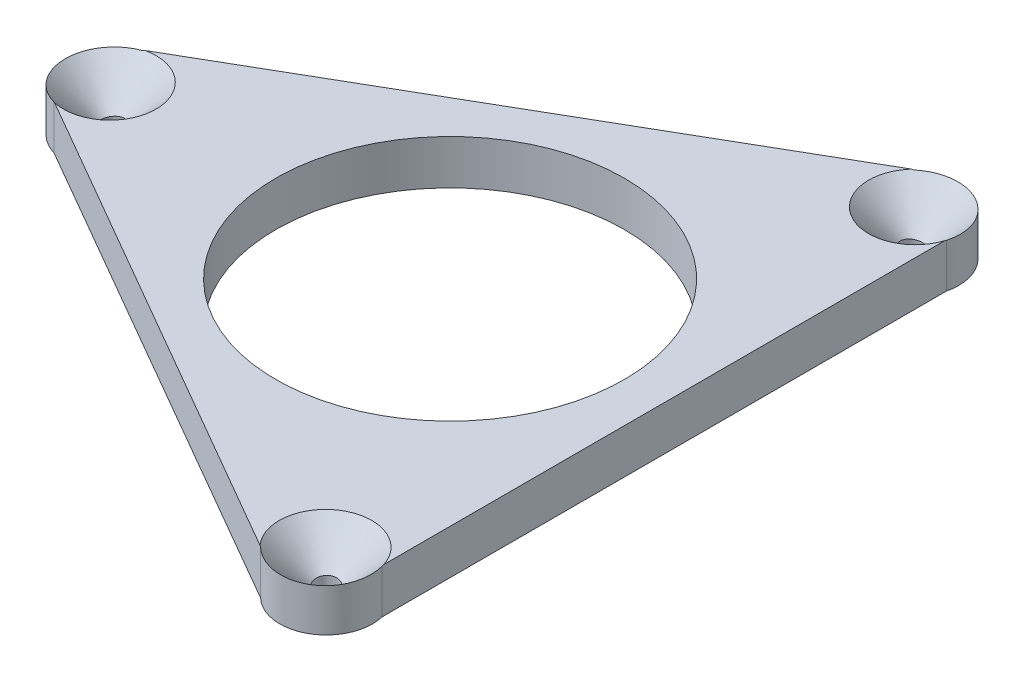
from build123d import *

# Parameters (mm, degrees)
SKETCH1_R           = 5.969
BOSS_EXTRUDE1_DEPTH = 1.524
CIRPATTERN1_COUNT   = 3
SKETCH4_R           = 0.381
CUT_EXTRUDE2_DEPTH  = 12.7


with BuildPart() as part:
    # Sketch1 → Boss-Extrude1 (new body)
    with BuildSketch(Plane(origin=(0, 0, 0), x_dir=(1, 0, 0), z_dir=(0, 1, 0))):
        with BuildLine():
            Line((-12.0345, -1.524), (4.697427285, -11.184182722))
            ThreePointArc((4.697427285, -11.184182722), (6.58875, -11.412049758), (7.337072715, -9.660182722))
            Line((7.337072715, -9.660182722), (7.337072715, 9.660182722))
            ThreePointArc((7.337072715, 9.660182722), (6.58875, 11.412049758), (4.697427285, 11.184182722))
            Line((4.697427285, 11.184182722), (-12.0345, 1.524))
            ThreePointArc((-12.0345, 1.524), (-13.1775, 0), (-12.0345, -1.524))
        make_face()
        with Locations(Location((0, 0, 0), (0, 0, 90))):
            Circle(SKETCH1_R, mode=Mode.SUBTRACT)
    extrude(amount=BOSS_EXTRUDE1_DEPTH)

    # Cut-Extrude1 cone 1 section (through the dimple's axis) → Cut-Extrude1 (revolve, cut)
    with BuildSketch(Plane(origin=(-11.65220136, 1.524, 0), x_dir=(0, 0, 1), z_dir=(1, 0, 0))):
        Polygon((0, 0), (1.5875, 0), (0, 1.5875), align=None)
    cut_extrude1 = revolve(axis=Axis((-11.65220136, 1.524, 0), (0, -1, 0)), mode=Mode.SUBTRACT)

    # CirPattern1: Cut-Extrude1 ×3 about axis
    cirpattern1_axis = Axis((0, 0, 0), (0, 1, 0))
    for i in range(1, CIRPATTERN1_COUNT):
        add(cut_extrude1.rotate(cirpattern1_axis, i * 360 / CIRPATTERN1_COUNT), mode=Mode.SUBTRACT)

    # Sketch4 → Cut-Extrude2 (cut)
    with BuildSketch(Plane.XZ):
        with Locations(Location((5.795, -10.03723443, 0), (0, 0, 270))):
            Circle(SKETCH4_R)
        with Locations(Location((-11.59, 0, 0), (0, 0, 270))):
            Circle(SKETCH4_R)
        with Locations(Location((5.795, 10.03723443, 0), (0, 0, 270))):
            Circle(SKETCH4_R)
    extrude(amount=-CUT_EXTRUDE2_DEPTH, mode=Mode.SUBTRACT)


solid = part.part
